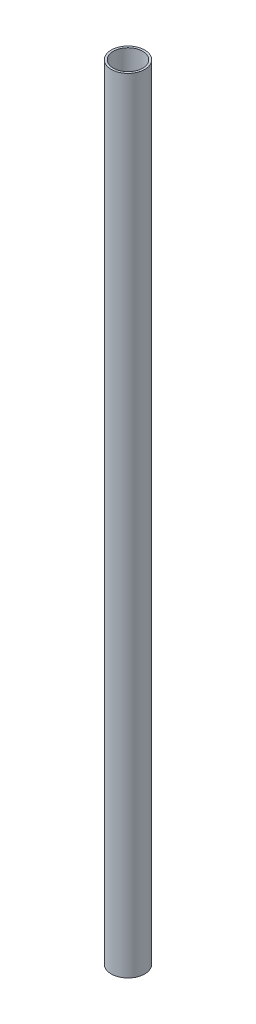
from build123d import *

# Parameters (mm, degrees)
SKETCH_1_R      = 6
SKETCH_1_R_2    = 5.25
EXTRUDE_1_DEPTH = 280


with BuildPart() as part:
    # Эскиз1 → Бобышка-Вытянуть1 (new body)
    with BuildSketch(Plane(origin=(0, 0, 0), x_dir=(1, 0, 0), z_dir=(0, 1, 0))):
        Circle(SKETCH_1_R)
        Circle(SKETCH_1_R_2, mode=Mode.SUBTRACT)
    extrude(amount=EXTRUDE_1_DEPTH)


solid = part.part
